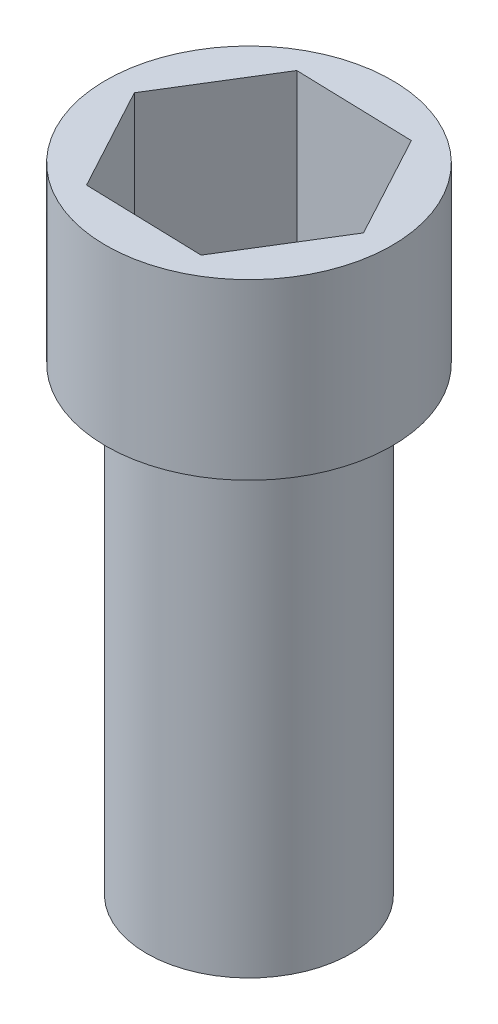
from build123d import *

# Parameters (mm, degrees)
SKETCH1_R           = 10
BOSS_EXTRUDE1_DEPTH = 45
SKETCH2_R           = 14
BOSS_EXTRUDE2_DEPTH = 2
SKETCH3_R           = 14
BOSS_EXTRUDE3_DEPTH = 15


with BuildPart() as part:
    # Sketch1 → Boss-Extrude1 (new body)
    with BuildSketch(Plane(origin=(0, 0, 0), x_dir=(1, 0, 0), z_dir=(0, 1, 0))):
        Circle(SKETCH1_R)
    extrude(amount=BOSS_EXTRUDE1_DEPTH)

    # Sketch2 → Boss-Extrude2 (add)
    with BuildSketch(Plane(origin=(0, 45, 0), x_dir=(1, 0, 0), z_dir=(0, 1, 0))):
        Circle(SKETCH2_R)
    extrude(amount=BOSS_EXTRUDE2_DEPTH)

    # Sketch3 → Boss-Extrude3 (add)
    with BuildSketch(Plane(origin=(0, 47, 0), x_dir=(1, 0, 0), z_dir=(0, 1, 0))):
        Circle(SKETCH3_R)
        Polygon((11.542222646, -0.332309673), (6.058899942, 9.829703191), (-5.483322704, 10.162012864), (-11.542222646, 0.332309673), (-6.058899942, -9.829703191), (5.483322704, -10.162012864), align=None, mode=Mode.SUBTRACT)
    extrude(amount=BOSS_EXTRUDE3_DEPTH)


solid = part.part
